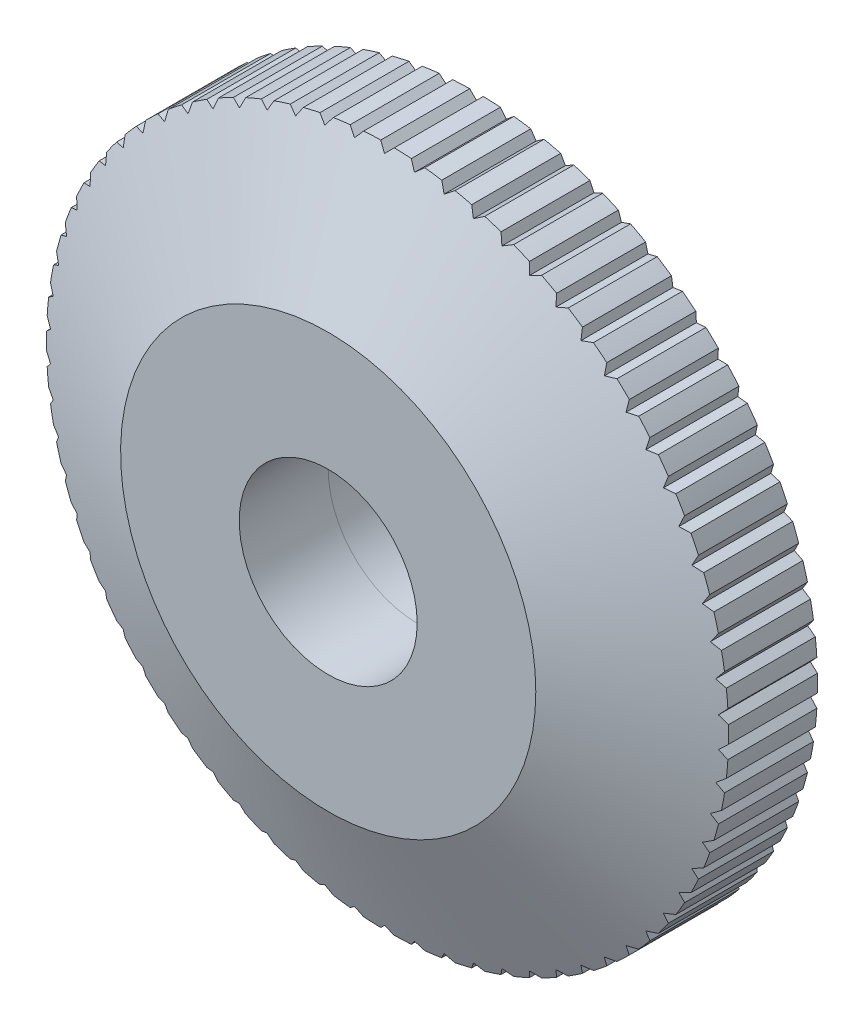
from build123d import *

# Parameters (mm, degrees)
SKETCH_1_R          = 11.5
EXTRUDE_1_DEPTH     = 3
SKETCH_2_R          = 7
SKETCH_3_R          = 11.5
SKETCH_4_R          = 10
CUT_EXTRUDE_1_DEPTH = 2
SKETCH_5_R          = 9.75
EXTRUDE_2_DEPTH     = 3
CUT_EXTRUDE_2_DEPTH = 6.0000001
SKETCH_8_R          = 3
CUT_EXTRUDE_3_DEPTH = 7


with BuildPart() as part:
    # Эскиз1 → Бобышка-Вытянуть1 (new body)
    with BuildSketch(Plane.XY):
        Circle(SKETCH_1_R)
    extrude(amount=EXTRUDE_1_DEPTH)

    # Эскиз2 → По сечениям2 section 0
    with BuildSketch(Plane.XY.offset(5)):
        Circle(SKETCH_2_R)
    # Эскиз3 → По сечениям2 section 1
    with BuildSketch(Plane.XY.offset(3)):
        Circle(SKETCH_3_R)
    loft()

    # Эскиз4 → Вырез-Вытянуть1 (cut)
    with BuildSketch(Plane(origin=(0, 0, 0), x_dir=(-1, 0, 0), z_dir=(0, 0, -1))):
        Circle(SKETCH_4_R)
    extrude(amount=-CUT_EXTRUDE_1_DEPTH, mode=Mode.SUBTRACT)

    # Эскиз6 → Вырез-Вытянуть2 (cut, through all)
    with BuildSketch(Plane(origin=(0, 0, 0), x_dir=(-1, 0, 0), z_dir=(0, 0, -1))):
        Polygon((-0.230209424, 11.5), (0, 11.269790576), (0.230209424, 11.5), align=None)
        Polygon((1.010216239, 11.224421712), (1.260134721, 11.433068567), (0.801569384, 11.474340195), align=None)
        Polygon((2.01229881, 11.088680405), (2.279914154, 11.274084789), (1.826894426, 11.356295749), align=None)
        Polygon((2.998179535, 10.863659563), (3.281337059, 11.024328709), (2.837510389, 11.146817087), align=None)
        Polygon((3.959920681, 10.551170922), (4.256340567, 10.685811216), (3.825280387, 10.847590808), align=None)
        Polygon((4.889778874, 10.153730457), (5.197074524, 10.261257855), (4.782251476, 10.461026107), align=None)
        Polygon((5.780267443, 9.674538124), (6.095964692, 9.754086879), (5.700718688, 9.990235374), align=None)
        Polygon((6.624216697, 9.117452099), (6.945773738, 9.168381731), (6.573287065, 9.43900914), align=None)
        Polygon((7.414831653, 8.486957711), (7.739659497, 8.508858164), (7.3929312, 8.811785554), align=None)
        Polygon((8.145746745, 7.788131329), (8.471230068, 7.780826274), (8.1530518, 8.113614653), align=None)
        Polygon((8.811077073, 7.026599493), (9.134595277, 6.990147746), (8.84752882, 7.350117697), align=None)
        Polygon((9.40546579, 6.20849361), (9.724414095, 6.143188659), (9.470770741, 6.527441915), align=None)
        Polygon((9.924127226, 5.340400587), (10.235937648, 5.246768228), (10.017759585, 5.652211009), align=None)
        Polygon((10.362885425, 4.429309798), (10.66504745, 4.308103905), (10.484091318, 4.731471823), align=None)
        Polygon((10.718207765, 3.482556811), (11.008288562, 3.334753263), (10.866011313, 3.772637608), align=None)
        Polygon((10.987233397, 2.507764324), (11.262897406, 2.334553147), (11.160444574, 2.783428334), align=None)
        Polygon((11.167796286, 1.512780794), (11.426824023, 1.315556583), (11.365020498, 1.771808531), align=None)
        Polygon((11.258442647, 0.505617242), (11.498748572, 0.285967931), (11.478091958, 0.745923167), align=None)
        Polygon((11.258442647, -0.505617242), (11.478091958, -0.745923167), (11.498748572, -0.285967931), align=None)
        Polygon((11.167796286, -1.512780794), (11.365020498, -1.771808531), (11.426824023, -1.315556583), align=None)
        Polygon((10.987233397, -2.507764324), (11.160444574, -2.783428334), (11.262897406, -2.334553147), align=None)
        Polygon((10.718207765, -3.482556811), (10.866011313, -3.772637608), (11.008288562, -3.334753263), align=None)
        Polygon((10.362885425, -4.429309798), (10.484091318, -4.731471823), (10.66504745, -4.308103905), align=None)
        Polygon((9.924127226, -5.340400587), (10.017759585, -5.652211009), (10.235937648, -5.246768228), align=None)
        Polygon((9.40546579, -6.20849361), (9.470770741, -6.527441915), (9.724414095, -6.143188659), align=None)
        Polygon((8.811077073, -7.026599493), (8.84752882, -7.350117697), (9.134595277, -6.990147746), align=None)
        Polygon((8.145746745, -7.788131329), (8.1530518, -8.113614653), (8.471230068, -7.780826274), align=None)
        Polygon((7.414831653, -8.486957711), (7.3929312, -8.811785554), (7.739659497, -8.508858164), align=None)
        Polygon((6.624216697, -9.117452099), (6.573287065, -9.43900914), (6.945773738, -9.168381731), align=None)
        Polygon((5.780267443, -9.674538124), (5.700718688, -9.990235374), (6.095964692, -9.754086879), align=None)
        Polygon((4.889778874, -10.153730457), (4.782251476, -10.461026107), (5.197074524, -10.261257855), align=None)
        Polygon((3.959920681, -10.551170922), (3.825280387, -10.847590808), (4.256340567, -10.685811216), align=None)
        Polygon((2.998179535, -10.863659563), (2.837510389, -11.146817087), (3.281337059, -11.024328709), align=None)
        Polygon((2.01229881, -11.088680405), (1.826894426, -11.356295749), (2.279914154, -11.274084789), align=None)
        Polygon((1.010216239, -11.224421712), (0.801569384, -11.474340195), (1.260134721, -11.433068567), align=None)
        Polygon((0, -11.269790576), (-0.230209424, -11.5), (0.230209424, -11.5), align=None)
        Polygon((-1.010216239, -11.224421712), (-1.260134721, -11.433068567), (-0.801569384, -11.474340195), align=None)
        Polygon((-2.01229881, -11.088680405), (-2.279914154, -11.274084789), (-1.826894426, -11.356295749), align=None)
        Polygon((-2.998179535, -10.863659563), (-3.281337059, -11.024328709), (-2.837510389, -11.146817087), align=None)
        Polygon((-3.959920681, -10.551170922), (-4.256340567, -10.685811216), (-3.825280387, -10.847590808), align=None)
        Polygon((-4.889778874, -10.153730457), (-5.197074524, -10.261257855), (-4.782251476, -10.461026107), align=None)
        Polygon((-5.780267443, -9.674538124), (-6.095964692, -9.754086879), (-5.700718688, -9.990235374), align=None)
        Polygon((-6.624216697, -9.117452099), (-6.945773738, -9.168381731), (-6.573287065, -9.43900914), align=None)
        Polygon((-7.414831653, -8.486957711), (-7.739659497, -8.508858164), (-7.3929312, -8.811785554), align=None)
        Polygon((-8.145746745, -7.788131329), (-8.471230068, -7.780826274), (-8.1530518, -8.113614653), align=None)
        Polygon((-8.811077073, -7.026599493), (-9.134595277, -6.990147746), (-8.84752882, -7.350117697), align=None)
        Polygon((-9.40546579, -6.20849361), (-9.724414095, -6.143188659), (-9.470770741, -6.527441915), align=None)
        Polygon((-9.924127226, -5.340400587), (-10.235937648, -5.246768228), (-10.017759585, -5.652211009), align=None)
        Polygon((-10.362885425, -4.429309798), (-10.66504745, -4.308103905), (-10.484091318, -4.731471823), align=None)
        Polygon((-10.718207765, -3.482556811), (-11.008288562, -3.334753263), (-10.866011313, -3.772637608), align=None)
        Polygon((-10.987233397, -2.507764324), (-11.262897406, -2.334553147), (-11.160444574, -2.783428334), align=None)
        Polygon((-11.167796286, -1.512780794), (-11.426824023, -1.315556583), (-11.365020498, -1.771808531), align=None)
        Polygon((-11.258442647, -0.505617242), (-11.498748572, -0.285967931), (-11.478091958, -0.745923167), align=None)
        Polygon((-11.258442647, 0.505617242), (-11.478091958, 0.745923167), (-11.498748572, 0.285967931), align=None)
        Polygon((-11.167796286, 1.512780794), (-11.365020498, 1.771808531), (-11.426824023, 1.315556583), align=None)
        Polygon((-10.987233397, 2.507764324), (-11.160444574, 2.783428334), (-11.262897406, 2.334553147), align=None)
        Polygon((-10.718207765, 3.482556811), (-10.866011313, 3.772637608), (-11.008288562, 3.334753263), align=None)
        Polygon((-10.362885425, 4.429309798), (-10.484091318, 4.731471823), (-10.66504745, 4.308103905), align=None)
        Polygon((-9.924127226, 5.340400587), (-10.017759585, 5.652211009), (-10.235937648, 5.246768228), align=None)
        Polygon((-9.40546579, 6.20849361), (-9.470770741, 6.527441915), (-9.724414095, 6.143188659), align=None)
        Polygon((-8.811077073, 7.026599493), (-8.84752882, 7.350117697), (-9.134595277, 6.990147746), align=None)
        Polygon((-8.145746745, 7.788131329), (-8.1530518, 8.113614653), (-8.471230068, 7.780826274), align=None)
        Polygon((-7.414831653, 8.486957711), (-7.3929312, 8.811785554), (-7.739659497, 8.508858164), align=None)
        Polygon((-6.624216697, 9.117452099), (-6.573287065, 9.43900914), (-6.945773738, 9.168381731), align=None)
        Polygon((-5.780267443, 9.674538124), (-5.700718688, 9.990235374), (-6.095964692, 9.754086879), align=None)
        Polygon((-4.889778874, 10.153730457), (-4.782251476, 10.461026107), (-5.197074524, 10.261257855), align=None)
        Polygon((-3.959920681, 10.551170922), (-3.825280387, 10.847590808), (-4.256340567, 10.685811216), align=None)
        Polygon((-2.998179535, 10.863659563), (-2.837510389, 11.146817087), (-3.281337059, 11.024328709), align=None)
        Polygon((-2.01229881, 11.088680405), (-1.826894426, 11.356295749), (-2.279914154, 11.274084789), align=None)
        Polygon((-1.010216239, 11.224421712), (-0.801569384, 11.474340195), (-1.260134721, 11.433068567), align=None)
    extrude(amount=-CUT_EXTRUDE_2_DEPTH, mode=Mode.SUBTRACT)


with BuildPart() as body_2:
    # Эскиз5 → Бобышка-Вытянуть2 (new body)
    with BuildSketch(Plane(origin=(0, 0, 2), x_dir=(-1, 0, 0), z_dir=(0, 0, -1))):
        Circle(SKETCH_5_R)
    extrude(amount=EXTRUDE_2_DEPTH)


with BuildPart() as cut_extrude_3_tool:
    # Эскиз8 → Вырез-Вытянуть3 (new body, through all)
    with BuildSketch(Plane.XY.offset(5)):
        Circle(SKETCH_8_R)
    extrude(amount=-CUT_EXTRUDE_3_DEPTH)


with BuildPart() as part_1:
    add(part.part)

    # Вырез-Вытянуть3: cut by cut_extrude_3_tool
    add(cut_extrude_3_tool.part, mode=Mode.SUBTRACT)


with BuildPart() as body_2_1:
    add(body_2.part)

    # Вырез-Вытянуть3: cut by cut_extrude_3_tool
    add(cut_extrude_3_tool.part, mode=Mode.SUBTRACT)


solid = Compound([part_1.part, body_2_1.part])
